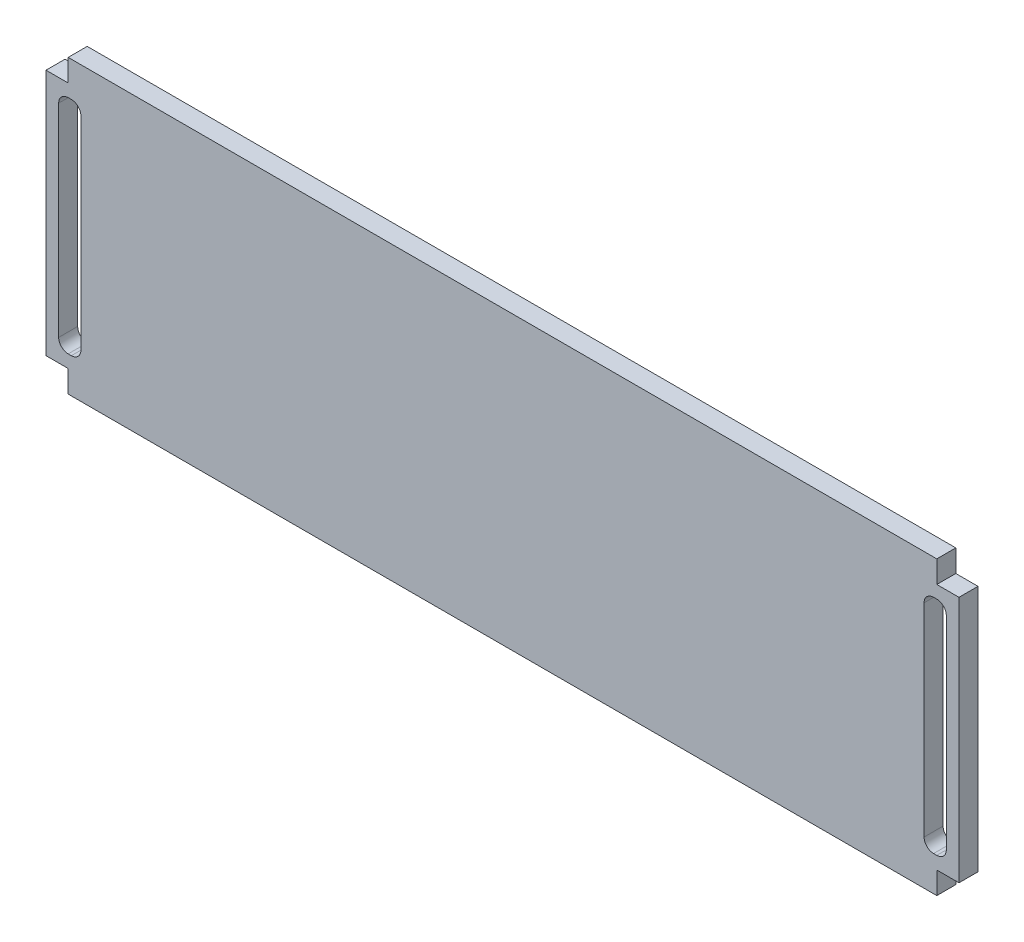
from build123d import *

# Parameters (mm, degrees)
BOSS_EXTRUDE1_DEPTH = 3
SKETCH2_W           = 3.5
SKETCH2_H           = 35
CUT_EXTRUDE7_DEPTH  = 3
FILLET5_R           = 1.5


with BuildPart() as part:
    # Sketch1 → Boss-Extrude1 (new body)
    with BuildSketch(Plane.XY):
        Polygon((68.5, 46), (-68.5, 46), (-68.5, 42.5), (-72, 42.5), (-72, 3.5), (-68.5, 3.5), (-68.5, 0), (68.5, 0), (68.5, 3.5), (72, 3.5), (72, 42.5), (68.5, 42.5), align=None)
    extrude(amount=BOSS_EXTRUDE1_DEPTH)

    # Sketch2 → Cut-Extrude7 (cut)
    with BuildSketch(Plane.XY.offset(3)):
        with Locations((-68.25, 23)):
            Rectangle(SKETCH2_W, SKETCH2_H)
        with Locations((68.25, 23)):
            Rectangle(SKETCH2_W, SKETCH2_H)
    extrude(amount=-CUT_EXTRUDE7_DEPTH, mode=Mode.SUBTRACT)

    # Fillet5
    fillet5_edges = [part.edges().sort_by_distance(p)[0] for p in [
        (-70, 5.5, 1.5),
        (-70, 40.5, 1.5),
        (-66.5, 40.5, 1.5),
        (-66.5, 5.5, 1.5),
        (70, 40.5, 1.5),
        (70, 5.5, 1.5),
        (66.5, 5.5, 1.5),
        (66.5, 40.5, 1.5),
    ]]
    fillet(fillet5_edges, radius=FILLET5_R)


solid = part.part
